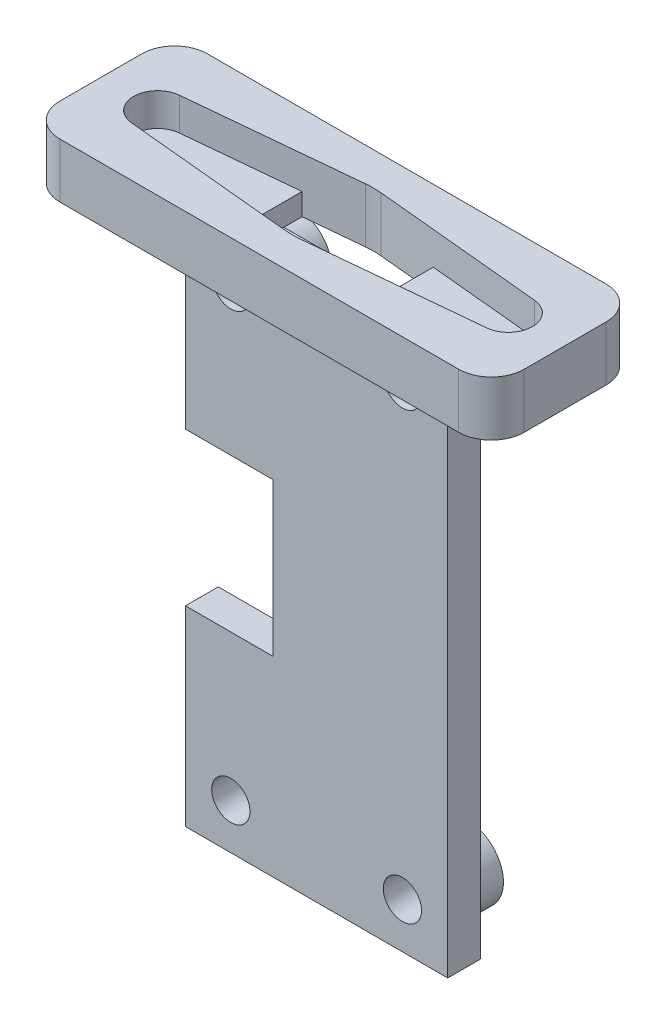
from build123d import *

# Parameters (mm, degrees)
BOSS_EXTRUDE1_DEPTH = 5
BOSS_EXTRUDE2_DEPTH = 2
SKETCH4_W           = 24
SKETCH4_H           = 3
BOSS_EXTRUDE3_DEPTH = 49
CUT_EXTRUDE1_REACH  = 10.25
SKETCH5_R           = 1.75
SKETCH5_W           = 8
SKETCH5_H           = 14
SKETCH6_R           = 3.25
SKETCH6_R_2         = 1.75
BOSS_EXTRUDE4_DEPTH = 3


with BuildPart() as part:
    # Sketch1 → Boss-Extrude1 (new body)
    with BuildSketch(Plane(origin=(0, 0, 0), x_dir=(1, 0, 0), z_dir=(0, 1, 0))):
        with BuildLine():
            Line((-18.25, 6.75), (18.25, 6.75))
            ThreePointArc((18.25, 6.75), (20.371320344, 5.871320344), (21.25, 3.75))
            Line((21.25, 3.75), (21.25, -3.75))
            ThreePointArc((21.25, -3.75), (20.371320344, -5.871320344), (18.25, -6.75))
            Line((18.25, -6.75), (-18.25, -6.75))
            ThreePointArc((-18.25, -6.75), (-20.371320344, -5.871320344), (-21.25, -3.75))
            Line((-21.25, -3.75), (-21.25, 3.75))
            ThreePointArc((-21.25, 3.75), (-20.371320344, 5.871320344), (-18.25, 6.75))
        make_face()
        with BuildLine():
            Line((16.260111444, 2.189943648), (0.716289014, 3.681276533))
            ThreePointArc((0.716289014, 3.681276533), (0, 3.715559552), (-0.716289014, 3.681276533))
            Line((-0.716289014, 3.681276533), (-16.260111444, 2.189943648))
            ThreePointArc((-16.260111444, 2.189943648), (-18.25, 0), (-16.260111444, -2.189943648))
            Line((-16.260111444, -2.189943648), (-0.716289014, -3.681276533))
            ThreePointArc((-0.716289014, -3.681276533), (0, -3.715559552), (0.716289014, -3.681276533))
            Line((0.716289014, -3.681276533), (16.260111444, -2.189943648))
            ThreePointArc((16.260111444, -2.189943648), (18.25, 0), (16.260111444, 2.189943648))
        make_face(mode=Mode.SUBTRACT)
    extrude(amount=BOSS_EXTRUDE1_DEPTH)

    # Sketch2 → Boss-Extrude2 (add)
    with BuildSketch(Plane.XZ):
        with BuildLine():
            Line((-16.260111444, 2.189943648), (-6, 3.174337395))
            Line((-6, 3.174337395), (-6, -3.174337395))
            Line((-6, -3.174337395), (-16.260111444, -2.189943648))
            ThreePointArc((-16.260111444, -2.189943648), (-18.25, 0), (-16.260111444, 2.189943648))
        make_face()
        with BuildLine():
            Line((6, -3.174337395), (16.260111444, -2.189943648))
            ThreePointArc((16.260111444, -2.189943648), (18.25, 0), (16.260111444, 2.189943648))
            Line((16.260111444, 2.189943648), (6, 3.174337395))
            Line((6, 3.174337395), (6, -3.174337395))
        make_face()
    extrude(amount=-BOSS_EXTRUDE2_DEPTH)

    # Sketch4 → Boss-Extrude3 (add)
    with BuildSketch(Plane.XZ):
        Rectangle(SKETCH4_W, SKETCH4_H)
    extrude(amount=BOSS_EXTRUDE3_DEPTH)

    # Sketch5 → Cut-Extrude1 (cut, up to next)
    with BuildSketch(Plane(origin=(0, 0, -1.5), x_dir=(-1, 0, 0), z_dir=(0, 0, -1)), mode=Mode.PRIVATE) as cut_extrude1_sk1:
        with Locations((7.85, -44.85)):
            Circle(SKETCH5_R)
    cut_extrude1_tool1 = extrude(cut_extrude1_sk1.sketch, amount=-CUT_EXTRUDE1_REACH, mode=Mode.PRIVATE) & part.part
    add(cut_extrude1_tool1.solids().sort_by_distance((-7.85, -44.85, -1.5))[0], mode=Mode.SUBTRACT)
    # Sketch5 → Cut-Extrude1 (cut, up to next)
    with BuildSketch(Plane(origin=(0, 0, -1.5), x_dir=(-1, 0, 0), z_dir=(0, 0, -1)), mode=Mode.PRIVATE) as cut_extrude1_sk2:
        with Locations((-7.85, -44.85)):
            Circle(SKETCH5_R)
    cut_extrude1_tool2 = extrude(cut_extrude1_sk2.sketch, amount=-CUT_EXTRUDE1_REACH, mode=Mode.PRIVATE) & part.part
    add(cut_extrude1_tool2.solids().sort_by_distance((7.85, -44.85, -1.5))[0], mode=Mode.SUBTRACT)
    # Sketch5 → Cut-Extrude1 (cut, up to next)
    with BuildSketch(Plane(origin=(0, 0, -1.5), x_dir=(-1, 0, 0), z_dir=(0, 0, -1)), mode=Mode.PRIVATE) as cut_extrude1_sk3:
        with Locations((-7.85, -4.15)):
            Circle(SKETCH5_R)
    cut_extrude1_tool3 = extrude(cut_extrude1_sk3.sketch, amount=-CUT_EXTRUDE1_REACH, mode=Mode.PRIVATE) & part.part
    add(cut_extrude1_tool3.solids().sort_by_distance((7.85, -4.15, -1.5))[0], mode=Mode.SUBTRACT)
    # Sketch5 → Cut-Extrude1 (cut, up to next)
    with BuildSketch(Plane(origin=(0, 0, -1.5), x_dir=(-1, 0, 0), z_dir=(0, 0, -1)), mode=Mode.PRIVATE) as cut_extrude1_sk4:
        with Locations((7.85, -4.15)):
            Circle(SKETCH5_R)
    cut_extrude1_tool4 = extrude(cut_extrude1_sk4.sketch, amount=-CUT_EXTRUDE1_REACH, mode=Mode.PRIVATE) & part.part
    add(cut_extrude1_tool4.solids().sort_by_distance((-7.85, -4.15, -1.5))[0], mode=Mode.SUBTRACT)
    # Sketch5 → Cut-Extrude1 (cut, up to next)
    with BuildSketch(Plane(origin=(0, 0, -1.5), x_dir=(-1, 0, 0), z_dir=(0, 0, -1)), mode=Mode.PRIVATE) as cut_extrude1_sk5:
        with Locations((8, -24.5)):
            Rectangle(SKETCH5_W, SKETCH5_H)
    cut_extrude1_tool5 = extrude(cut_extrude1_sk5.sketch, amount=-CUT_EXTRUDE1_REACH, mode=Mode.PRIVATE) & part.part
    add(cut_extrude1_tool5.solids().sort_by_distance((-8, -24.5, -1.5))[0], mode=Mode.SUBTRACT)

    # Sketch6 → Boss-Extrude4 (add)
    with BuildSketch(Plane(origin=(0, 0, -1.5), x_dir=(-1, 0, 0), z_dir=(0, 0, -1))):
        with Locations((-7.85, -4.15)):
            Circle(SKETCH6_R)
        with Locations((-7.85, -4.15)):
            Circle(SKETCH6_R_2, mode=Mode.SUBTRACT)
        with Locations((7.85, -4.15)):
            Circle(SKETCH6_R)
        with Locations((7.85, -4.15)):
            Circle(SKETCH6_R_2, mode=Mode.SUBTRACT)
        with Locations((7.85, -44.85)):
            Circle(SKETCH6_R)
        with Locations((7.85, -44.85)):
            Circle(SKETCH6_R_2, mode=Mode.SUBTRACT)
        with Locations((-7.85, -44.85)):
            Circle(SKETCH6_R)
        with Locations((-7.85, -44.85)):
            Circle(SKETCH6_R_2, mode=Mode.SUBTRACT)
    extrude(amount=BOSS_EXTRUDE4_DEPTH)


solid = part.part
